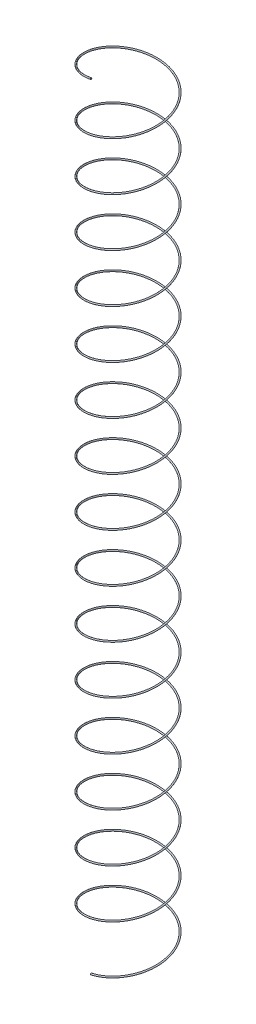
from build123d import *

# Parameters (mm, degrees)
DEPLOYED_PITCH  = 28.6
DEPLOYED_HEIGHT = 457.6
DEPLOYED_RADIUS = 21.75
SKETCH7_R       = 0.405


with BuildPart() as part:
    # Deployed: sweep along a helix
    with BuildLine() as deployed_path:
        Helix(DEPLOYED_PITCH, DEPLOYED_HEIGHT, DEPLOYED_RADIUS, center=(0, 0, 0), direction=(0, 1, 0))
    # Sketch7 → Deployed (sweep)
    with BuildSketch(Plane(origin=(0, 0, 0), x_dir=(0, 0, -1), z_dir=(1, 0, 0))):
        with Locations((-21.75, 0)):
            Circle(SKETCH7_R)
    sweep(path=deployed_path.line, is_frenet=True)


solid = part.part
